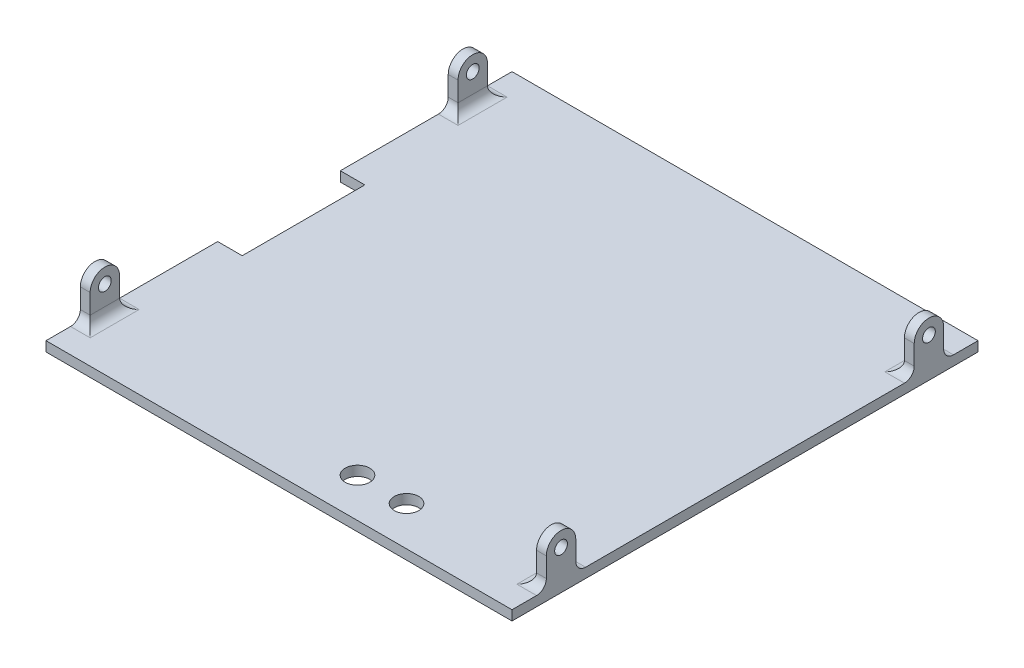
from build123d import *

# Parameters (mm, degrees)
SKETCH1_W           = 95
SKETCH1_H           = 95
BOSS_EXTRUDE1_DEPTH = 2
SKETCH2_W           = 2
SKETCH2_H           = 6
BOSS_EXTRUDE2_DEPTH = 6
SKETCH3_R           = 3
BOSS_EXTRUDE3_DEPTH = 2
SKETCH6_R           = 3
BOSS_EXTRUDE5_DEPTH = 2
SKETCH8_R           = 1.3
CUT_EXTRUDE2_DEPTH  = 96
FILLET1_R           = 2
SKETCH10_W          = 25
SKETCH10_H          = 4
CUT_EXTRUDE3_DEPTH  = 5
SKETCH11_R          = 2.5
CUT_EXTRUDE4_DEPTH  = 2


with BuildPart() as part:
    # Sketch1 → Boss-Extrude1 (new body)
    with BuildSketch(Plane(origin=(0, 0, 0), x_dir=(1, 0, 0), z_dir=(0, 1, 0))):
        Rectangle(SKETCH1_W, SKETCH1_H)
    extrude(amount=BOSS_EXTRUDE1_DEPTH)

    # Sketch2 → Boss-Extrude2 (add)
    with BuildSketch(Plane(origin=(0, 2, 0), x_dir=(1, 0, 0), z_dir=(0, 1, 0))):
        with Locations((-46.5, -37.5)):
            Rectangle(SKETCH2_W, SKETCH2_H)
        with Locations((-46.5, 37.5)):
            Rectangle(SKETCH2_W, SKETCH2_H)
        with Locations((46.5, -37.5)):
            Rectangle(SKETCH2_W, SKETCH2_H)
        with Locations((46.5, 37.5)):
            Rectangle(SKETCH2_W, SKETCH2_H)
    extrude(amount=BOSS_EXTRUDE2_DEPTH)

    # Sketch3 → Boss-Extrude3 (add)
    with BuildSketch(Plane(origin=(-45.5, 0, 0), x_dir=(0, 0, -1), z_dir=(1, 0, 0))):
        with Locations((-37.5, 8)):
            Circle(SKETCH3_R)
        with Locations((37.5, 8)):
            Circle(SKETCH3_R)
    extrude(amount=-BOSS_EXTRUDE3_DEPTH)

    # Sketch6 → Boss-Extrude5 (add)
    with BuildSketch(Plane.ZY.offset(-45.5)):
        with Locations((-37.5, 8)):
            Circle(SKETCH6_R)
        with Locations((37.5, 8)):
            Circle(SKETCH6_R)
    extrude(amount=-BOSS_EXTRUDE5_DEPTH)

    # Sketch8 → Cut-Extrude2 (cut, through all)
    with BuildSketch(Plane.ZY.offset(47.5)):
        with Locations((-37.5, 8)):
            Circle(SKETCH8_R)
        with Locations((37.5, 8)):
            Circle(SKETCH8_R)
    extrude(amount=-CUT_EXTRUDE2_DEPTH, mode=Mode.SUBTRACT)

    # Fillet1
    fillet1_edges = [part.edges().sort_by_distance(p)[0] for p in [
        (-46.5, 2, 40.5),
        (-45.5, 2, 37.5),
        (-46.5, 2, 34.5),
        (-46.5, 2, -34.5),
        (-45.5, 2, -37.5),
        (-46.5, 2, -40.5),
        (46.5, 2, 34.5),
        (45.5, 2, 37.5),
        (46.5, 2, 40.5),
        (46.5, 2, -40.5),
        (45.5, 2, -37.5),
        (46.5, 2, -34.5),
    ]]
    fillet(fillet1_edges, radius=FILLET1_R)

    # Sketch10 → Cut-Extrude3 (cut)
    with BuildSketch(Plane.ZY.offset(47.5)):
        Rectangle(SKETCH10_W, SKETCH10_H)
    extrude(amount=-CUT_EXTRUDE3_DEPTH, mode=Mode.SUBTRACT)

    # Sketch11 → Cut-Extrude4 (cut)
    with BuildSketch(Plane(origin=(0, 2, 0), x_dir=(1, 0, 0), z_dir=(0, 1, 0))):
        with Locations((18, -39.5)):
            Circle(SKETCH11_R)
        with Locations((8, -39.5)):
            Circle(SKETCH11_R)
    extrude(amount=-CUT_EXTRUDE4_DEPTH, mode=Mode.SUBTRACT)


solid = part.part
